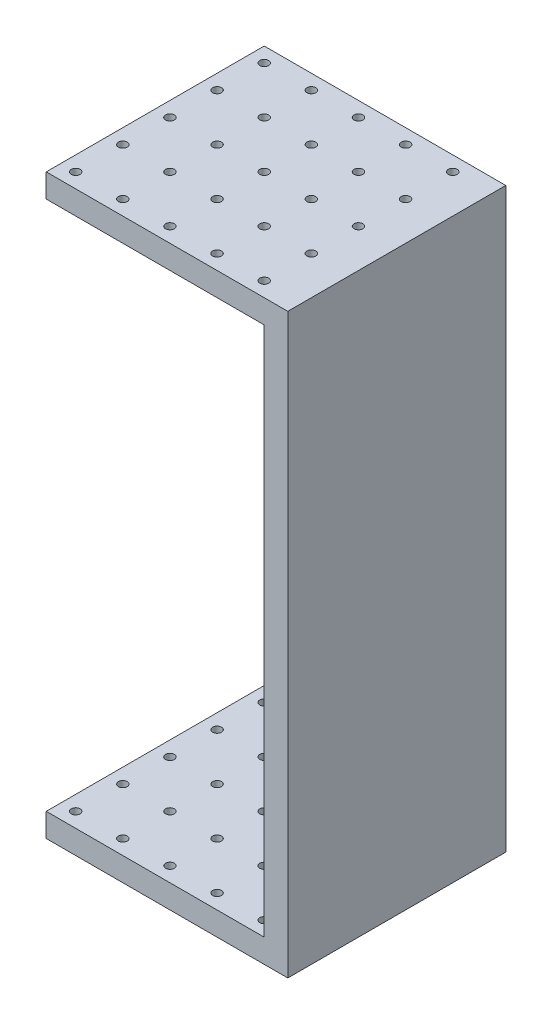
from build123d import *

# Parameters (mm, degrees)
SKETCH1_W           = 20.5
SKETCH1_H           = 18.5
BOSS_EXTRUDE1_DEPTH = 2
SKETCH2_W           = 2
SKETCH2_H           = 18.5
BOSS_EXTRUDE2_DEPTH = 45
SKETCH4_W           = 20.5
SKETCH4_H           = 18.5
BOSS_EXTRUDE3_DEPTH = 2
SKETCH3_R           = 0.375
CUT_EXTRUDE1_DEPTH  = 50


with BuildPart() as part:
    # Sketch1 → Boss-Extrude1 (new body)
    with BuildSketch(Plane(origin=(0, 0, 0), x_dir=(1, 0, 0), z_dir=(0, 1, 0))):
        Rectangle(SKETCH1_W, SKETCH1_H)
    extrude(amount=BOSS_EXTRUDE1_DEPTH)

    # Sketch2 → Boss-Extrude2 (add)
    with BuildSketch(Plane(origin=(0, 2, 0), x_dir=(1, 0, 0), z_dir=(0, 1, 0))):
        with Locations((9.25, 0)):
            Rectangle(SKETCH2_W, SKETCH2_H)
    extrude(amount=BOSS_EXTRUDE2_DEPTH)

    # Sketch4 → Boss-Extrude3 (add)
    with BuildSketch(Plane(origin=(0, 47, 0), x_dir=(1, 0, 0), z_dir=(0, 1, 0))):
        Rectangle(SKETCH4_W, SKETCH4_H)
    extrude(amount=BOSS_EXTRUDE3_DEPTH)

    # Sketch3 → Cut-Extrude1 (cut, through all)
    with BuildSketch(Plane.XZ):
        with Locations((-9, 8)):
            Circle(SKETCH3_R)
        with Locations((-5, 8)):
            Circle(SKETCH3_R)
        with Locations((-1, 8)):
            Circle(SKETCH3_R)
        with Locations((3, 8)):
            Circle(SKETCH3_R)
        with Locations((7, 8)):
            Circle(SKETCH3_R)
        with Locations((-5, 4)):
            Circle(SKETCH3_R)
        with Locations((-1, 4)):
            Circle(SKETCH3_R)
        with Locations((3, 4)):
            Circle(SKETCH3_R)
        with Locations((7, 4)):
            Circle(SKETCH3_R)
        with Locations((-5, 0)):
            Circle(SKETCH3_R)
        with Locations((-1, 0)):
            Circle(SKETCH3_R)
        with Locations((3, 0)):
            Circle(SKETCH3_R)
        with Locations((7, 0)):
            Circle(SKETCH3_R)
        with Locations((-5, -4)):
            Circle(SKETCH3_R)
        with Locations((-1, -4)):
            Circle(SKETCH3_R)
        with Locations((3, -4)):
            Circle(SKETCH3_R)
        with Locations((7, -4)):
            Circle(SKETCH3_R)
        with Locations((-5, -8)):
            Circle(SKETCH3_R)
        with Locations((-1, -8)):
            Circle(SKETCH3_R)
        with Locations((3, -8)):
            Circle(SKETCH3_R)
        with Locations((7, -8)):
            Circle(SKETCH3_R)
        with Locations((-5, -12)):
            Circle(SKETCH3_R)
        with Locations((-1, -12)):
            Circle(SKETCH3_R)
        with Locations((3, -12)):
            Circle(SKETCH3_R)
        with Locations((7, -12)):
            Circle(SKETCH3_R)
        with Locations((-9, 4)):
            Circle(SKETCH3_R)
        with Locations((-9, 0)):
            Circle(SKETCH3_R)
        with Locations((-9, -4)):
            Circle(SKETCH3_R)
        with Locations((-9, -8)):
            Circle(SKETCH3_R)
        with Locations((-9, -12)):
            Circle(SKETCH3_R)
    extrude(amount=-CUT_EXTRUDE1_DEPTH, mode=Mode.SUBTRACT)


solid = part.part
